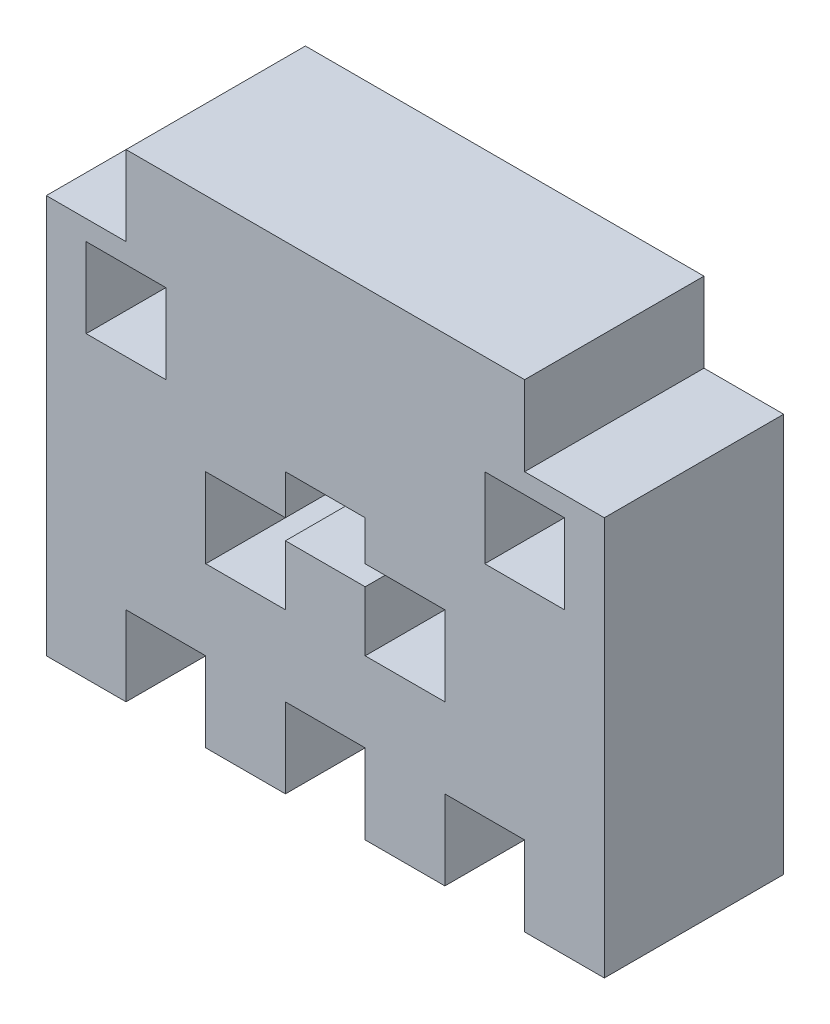
from build123d import *

# Parameters (mm, degrees)
SKETCH1_W      = 20
SKETCH1_H      = 20
EXTRUDE1_DEPTH = 45


with BuildPart() as part:
    # Sketch1 → Extrude1 (new body)
    with BuildSketch(Plane.XY):
        Polygon((20, 0), (20, 20), (40, 20), (40, 0), (60, 0), (60, 20), (80, 20), (80, 0), (100, 0), (100, 20), (120, 20), (120, 0), (140, 0), (140, 100), (120, 100), (120, 120), (20, 120), (20, 100), (0, 100), (0, 0), align=None)
        with Locations((20, 85)):
            Rectangle(SKETCH1_W, SKETCH1_H, mode=Mode.SUBTRACT)
        with Locations((120, 85)):
            Rectangle(SKETCH1_W, SKETCH1_H, mode=Mode.SUBTRACT)
        Polygon((40, 40), (60, 40), (60, 55), (80, 55), (80, 40), (100, 40), (100, 60), (80, 60), (80, 70), (60, 70), (60, 60), (40, 60), align=None, mode=Mode.SUBTRACT)
    extrude(amount=EXTRUDE1_DEPTH)


solid = part.part
